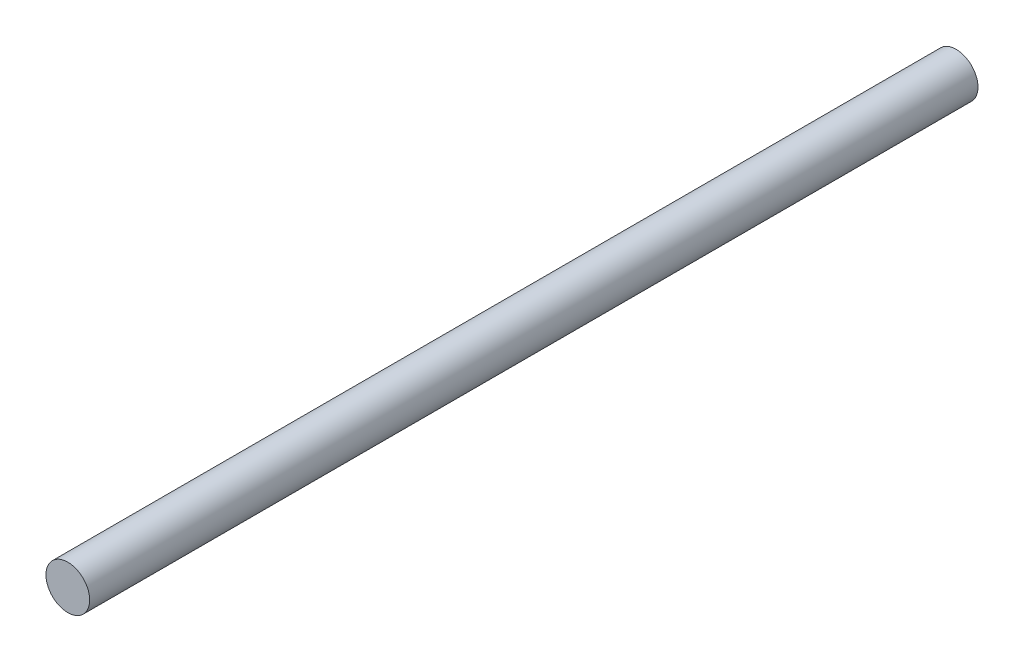
from build123d import *

# Parameters (mm, degrees)
SKETCH1_R           = 8
BOSS_EXTRUDE1_DEPTH = 162.5


with BuildPart() as part:
    # Sketch1 → Boss-Extrude1 (new body, symmetric)
    with BuildSketch(Plane.XY):
        Circle(SKETCH1_R)
    extrude(amount=BOSS_EXTRUDE1_DEPTH, both=True)


solid = part.part
